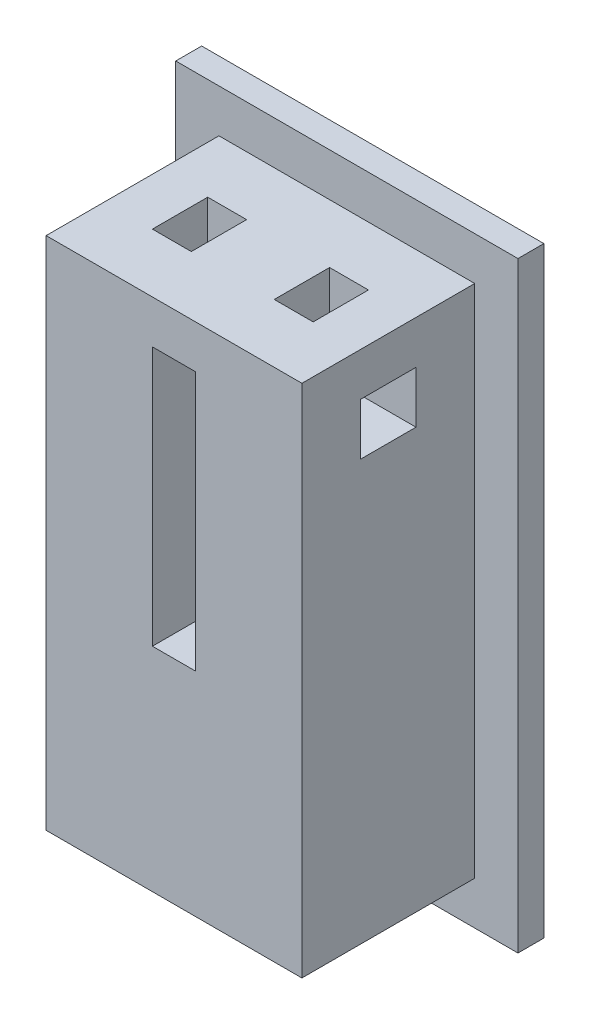
from build123d import *

# Parameters (mm, degrees)
SKETCH_1_W          = 29.6
SKETCH_1_H          = 59.6
SKETCH_1_W_2        = 5
SKETCH_1_H_2        = 30
EXTRUDE_1_DEPTH     = 20
SKETCH_2_W          = 39.6
SKETCH_2_H          = 69.6
SKETCH_2_W_2        = 5
SKETCH_2_H_2        = 30
EXTRUDE_2_DEPTH     = 3
SKETCH_3_W          = 4.5
SKETCH_3_H          = 6.4
CUT_EXTRUDE_1_DEPTH = 11
SKETCH_5_W          = 6.4
SKETCH_5_H          = 6
CUT_EXTRUDE_2_DEPTH = 35.6


with BuildPart() as part:
    # 스케치1 → 보스-돌출1 (new body)
    with BuildSketch(Plane.XY):
        Rectangle(SKETCH_1_W, SKETCH_1_H)
        with Locations((0, 9.8)):
            Rectangle(SKETCH_1_W_2, SKETCH_1_H_2, mode=Mode.SUBTRACT)
    extrude(amount=EXTRUDE_1_DEPTH)

    # 스케치2 → 보스-돌출2 (add)
    with BuildSketch(Plane(origin=(0, 0, 0), x_dir=(-1, 0, 0), z_dir=(0, 0, -1))):
        Rectangle(SKETCH_2_W, SKETCH_2_H)
        with Locations((0, 9.8)):
            Rectangle(SKETCH_2_W_2, SKETCH_2_H_2, mode=Mode.SUBTRACT)
    extrude(amount=EXTRUDE_2_DEPTH)

    # 스케치3 → 컷-돌출1 (cut)
    with BuildSketch(Plane(origin=(0, 29.8, 0), x_dir=(1, 0, 0), z_dir=(0, 1, 0))):
        with Locations((-7.05, -10)):
            Rectangle(SKETCH_3_W, SKETCH_3_H)
        with Locations((7.05, -10)):
            Rectangle(SKETCH_3_W, SKETCH_3_H)
    extrude(amount=-CUT_EXTRUDE_1_DEPTH, mode=Mode.SUBTRACT)

    # 스케치5 → 컷-돌출2 (cut, through all)
    with BuildSketch(Plane.ZY.offset(14.8)):
        with Locations((10, 21.8)):
            Rectangle(SKETCH_5_W, SKETCH_5_H)
    extrude(amount=-CUT_EXTRUDE_2_DEPTH, mode=Mode.SUBTRACT)


solid = part.part
